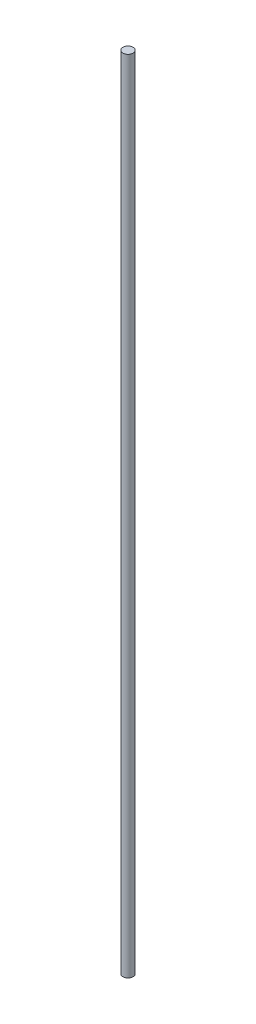
from build123d import *

# Parameters (mm, degrees)
SKETCH1_R           = 20
BOSS_EXTRUDE1_DEPTH = 3131.82


with BuildPart() as part:
    # Sketch1 → Boss-Extrude1 (new body)
    with BuildSketch(Plane(origin=(0, 0, 0), x_dir=(1, 0, 0), z_dir=(0, 1, 0))):
        Circle(SKETCH1_R)
    extrude(amount=BOSS_EXTRUDE1_DEPTH)


solid = part.part
